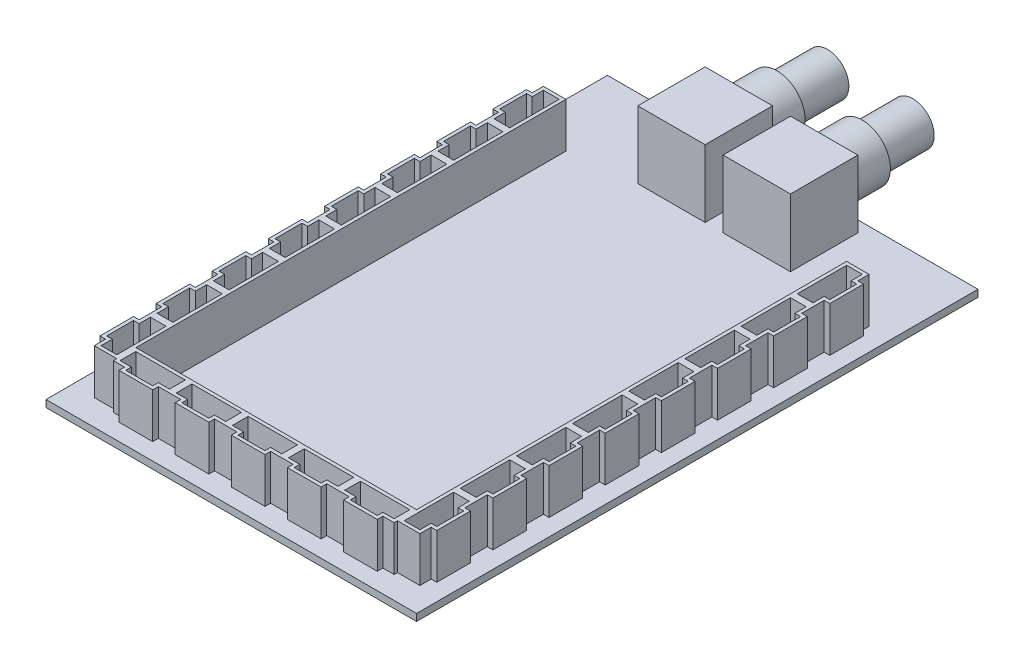
from build123d import *

# Parameters (mm, degrees)
SKETCH1_W            = 83.82
SKETCH1_H            = 127
BOSS_EXTRUDE1_DEPTH  = 1.5875
SKETCH2_W            = 15.24
SKETCH2_H            = 15.24
BNC_BASE_DEPTH       = 15.24
SKETCH3_R            = 6.35
BNC_SHAFT_DEPTH      = 8.636
SKETCH4_R            = 4.826
SKETCH4_R_2          = 4.191
BNC_SHIELD_DEPTH     = 11.43
SKETCH5_W            = 2.413
SKETCH5_H            = 15.748
SKETCH5_H_2          = 20.828
BASEHEADERS_DEPTH    = 2.413
BOSS_EXTRUDE6_DEPTH  = 10.16
LPATTERN1_COUNT      = 8
LPATTERN1_PITCH      = 12.7
MIRROR1_COPY_1_DEPTH = 10.16
MIRROR1_COPY_2_DEPTH = 10.16
MIRROR1_COPY_3_DEPTH = 10.16
MIRROR1_COPY_4_DEPTH = 10.16
MIRROR1_COPY_5_DEPTH = 10.16
MIRROR1_COPY_6_DEPTH = 10.16
MIRROR1_COPY_7_DEPTH = 10.16
BOSS_EXTRUDE7_DEPTH  = 10.16
LPATTERN2_COUNT      = 5
LPATTERN2_PITCH      = 12.7


with BuildPart() as part:
    # Sketch1 → Boss-Extrude1 (new body)
    with BuildSketch(Plane(origin=(0, 0, 0), x_dir=(1, 0, 0), z_dir=(0, 1, 0))):
        Rectangle(SKETCH1_W, SKETCH1_H)
    extrude(amount=BOSS_EXTRUDE1_DEPTH)

    # Sketch2 → BNC Base (add)
    with BuildSketch(Plane(origin=(0, 1.5875, 0), x_dir=(1, 0, 0), z_dir=(0, 1, 0))):
        with Locations((-9.652, 53.34)):
            Rectangle(SKETCH2_W, SKETCH2_H)
        with Locations((9.652, 53.34)):
            Rectangle(SKETCH2_W, SKETCH2_H)
    extrude(amount=BNC_BASE_DEPTH)

    # Sketch3 → BNC Shaft (add)
    with BuildSketch(Plane(origin=(0, 0, -60.96), x_dir=(-1, 0, 0), z_dir=(0, 0, -1))):
        with Locations((-9.652, 9.2075)):
            Circle(SKETCH3_R)
        with Locations((9.652, 9.2075)):
            Circle(SKETCH3_R)
    extrude(amount=BNC_SHAFT_DEPTH)

    # Sketch4 → BNC Shield (add)
    with BuildSketch(Plane(origin=(0, 0, -69.596), x_dir=(-1, 0, 0), z_dir=(0, 0, -1))):
        with Locations((-9.652, 9.2075)):
            Circle(SKETCH4_R)
        with Locations((-9.652, 9.2075)):
            Circle(SKETCH4_R_2, mode=Mode.SUBTRACT)
        with Locations((9.652, 9.2075)):
            Circle(SKETCH4_R)
        with Locations((9.652, 9.2075)):
            Circle(SKETCH4_R_2, mode=Mode.SUBTRACT)
    extrude(amount=BNC_SHIELD_DEPTH)

    # Sketch5 → BaseHeaders (add)
    with BuildSketch(Plane.XZ):
        with Locations((-24.13, -24.13)):
            Rectangle(SKETCH5_W, SKETCH5_H)
        with Locations((24.13, -30.734)):
            Rectangle(SKETCH5_W, SKETCH5_H_2)
        with Locations((24.13, -8.89)):
            Rectangle(SKETCH5_W, SKETCH5_H_2)
        with Locations((24.13, 13.97)):
            Rectangle(SKETCH5_W, SKETCH5_H_2)
        with Locations((-24.13, -3.81)):
            Rectangle(SKETCH5_W, SKETCH5_H_2)
        with Locations((-24.13, 19.05)):
            Rectangle(SKETCH5_W, SKETCH5_H_2)
    extrude(amount=BASEHEADERS_DEPTH)

    # Sketch6 → Boss-Extrude6 (add)
    with BuildSketch(Plane(origin=(0, 1.5875, 0), x_dir=(1, 0, 0), z_dir=(0, 1, 0))):
        Polygon((-36.83, 43.942), (-31.75, 43.942), (-31.75, 31.242), (-36.83, 31.242), (-36.83, 33.782), (-38.1, 33.782), (-38.1, 41.402), (-36.83, 41.402), align=None)
        Polygon((-37.338, 34.544), (-37.338, 40.64), (-36.068, 40.64), (-36.068, 43.18), (-32.512, 43.18), (-32.512, 32.004), (-36.068, 32.004), (-36.068, 34.544), align=None, mode=Mode.SUBTRACT)
    boss_extrude6 = extrude(amount=BOSS_EXTRUDE6_DEPTH)

    # LPattern1: Boss-Extrude6 ×8
    with Locations(*[(0, 0, i * LPATTERN1_PITCH) for i in range(1, LPATTERN1_COUNT)]):
        add(boss_extrude6)

    # Mirror1: Boss-Extrude6 across plane
    add(boss_extrude6.mirror(Plane(origin=(0, 0, 0), x_dir=(0, 0, 1), z_dir=(1, 0, 0))))

    # Mirror1 copy 1 sketch → Mirror1 copy 1 (add)
    with BuildSketch(Plane(origin=(0, 1.5875, 12.7), x_dir=(-1, 0, 0), z_dir=(0, 1, 0))):
        Polygon((-36.83, -43.942), (-31.75, -43.942), (-31.75, -31.242), (-36.83, -31.242), (-36.83, -33.782), (-38.1, -33.782), (-38.1, -41.402), (-36.83, -41.402), align=None)
        Polygon((-37.338, -34.544), (-37.338, -40.64), (-36.068, -40.64), (-36.068, -43.18), (-32.512, -43.18), (-32.512, -32.004), (-36.068, -32.004), (-36.068, -34.544), align=None, mode=Mode.SUBTRACT)
    extrude(amount=MIRROR1_COPY_1_DEPTH)

    # Mirror1 copy 2 sketch → Mirror1 copy 2 (add)
    with BuildSketch(Plane(origin=(0, 1.5875, 25.4), x_dir=(-1, 0, 0), z_dir=(0, 1, 0))):
        Polygon((-36.83, -43.942), (-31.75, -43.942), (-31.75, -31.242), (-36.83, -31.242), (-36.83, -33.782), (-38.1, -33.782), (-38.1, -41.402), (-36.83, -41.402), align=None)
        Polygon((-37.338, -34.544), (-37.338, -40.64), (-36.068, -40.64), (-36.068, -43.18), (-32.512, -43.18), (-32.512, -32.004), (-36.068, -32.004), (-36.068, -34.544), align=None, mode=Mode.SUBTRACT)
    extrude(amount=MIRROR1_COPY_2_DEPTH)

    # Mirror1 copy 3 sketch → Mirror1 copy 3 (add)
    with BuildSketch(Plane(origin=(0, 1.5875, 38.1), x_dir=(-1, 0, 0), z_dir=(0, 1, 0))):
        Polygon((-36.83, -43.942), (-31.75, -43.942), (-31.75, -31.242), (-36.83, -31.242), (-36.83, -33.782), (-38.1, -33.782), (-38.1, -41.402), (-36.83, -41.402), align=None)
        Polygon((-37.338, -34.544), (-37.338, -40.64), (-36.068, -40.64), (-36.068, -43.18), (-32.512, -43.18), (-32.512, -32.004), (-36.068, -32.004), (-36.068, -34.544), align=None, mode=Mode.SUBTRACT)
    extrude(amount=MIRROR1_COPY_3_DEPTH)

    # Mirror1 copy 4 sketch → Mirror1 copy 4 (add)
    with BuildSketch(Plane(origin=(0, 1.5875, 50.8), x_dir=(-1, 0, 0), z_dir=(0, 1, 0))):
        Polygon((-36.83, -43.942), (-31.75, -43.942), (-31.75, -31.242), (-36.83, -31.242), (-36.83, -33.782), (-38.1, -33.782), (-38.1, -41.402), (-36.83, -41.402), align=None)
        Polygon((-37.338, -34.544), (-37.338, -40.64), (-36.068, -40.64), (-36.068, -43.18), (-32.512, -43.18), (-32.512, -32.004), (-36.068, -32.004), (-36.068, -34.544), align=None, mode=Mode.SUBTRACT)
    extrude(amount=MIRROR1_COPY_4_DEPTH)

    # Mirror1 copy 5 sketch → Mirror1 copy 5 (add)
    with BuildSketch(Plane(origin=(0, 1.5875, 63.5), x_dir=(-1, 0, 0), z_dir=(0, 1, 0))):
        Polygon((-36.83, -43.942), (-31.75, -43.942), (-31.75, -31.242), (-36.83, -31.242), (-36.83, -33.782), (-38.1, -33.782), (-38.1, -41.402), (-36.83, -41.402), align=None)
        Polygon((-37.338, -34.544), (-37.338, -40.64), (-36.068, -40.64), (-36.068, -43.18), (-32.512, -43.18), (-32.512, -32.004), (-36.068, -32.004), (-36.068, -34.544), align=None, mode=Mode.SUBTRACT)
    extrude(amount=MIRROR1_COPY_5_DEPTH)

    # Mirror1 copy 6 sketch → Mirror1 copy 6 (add)
    with BuildSketch(Plane(origin=(0, 1.5875, 76.2), x_dir=(-1, 0, 0), z_dir=(0, 1, 0))):
        Polygon((-36.83, -43.942), (-31.75, -43.942), (-31.75, -31.242), (-36.83, -31.242), (-36.83, -33.782), (-38.1, -33.782), (-38.1, -41.402), (-36.83, -41.402), align=None)
        Polygon((-37.338, -34.544), (-37.338, -40.64), (-36.068, -40.64), (-36.068, -43.18), (-32.512, -43.18), (-32.512, -32.004), (-36.068, -32.004), (-36.068, -34.544), align=None, mode=Mode.SUBTRACT)
    extrude(amount=MIRROR1_COPY_6_DEPTH)

    # Mirror1 copy 7 sketch → Mirror1 copy 7 (add)
    with BuildSketch(Plane(origin=(0, 1.5875, 88.9), x_dir=(-1, 0, 0), z_dir=(0, 1, 0))):
        Polygon((-36.83, -43.942), (-31.75, -43.942), (-31.75, -31.242), (-36.83, -31.242), (-36.83, -33.782), (-38.1, -33.782), (-38.1, -41.402), (-36.83, -41.402), align=None)
        Polygon((-37.338, -34.544), (-37.338, -40.64), (-36.068, -40.64), (-36.068, -43.18), (-32.512, -43.18), (-32.512, -32.004), (-36.068, -32.004), (-36.068, -34.544), align=None, mode=Mode.SUBTRACT)
    extrude(amount=MIRROR1_COPY_7_DEPTH)

    # Sketch7 → Boss-Extrude7 (add)
    with BuildSketch(Plane(origin=(0, 1.5875, 0), x_dir=(1, 0, 0), z_dir=(0, 1, 0))):
        Polygon((-31.75, -58.42), (-31.75, -53.34), (-19.05, -53.34), (-19.05, -58.42), (-21.59, -58.42), (-21.59, -59.69), (-29.21, -59.69), (-29.21, -58.42), align=None)
        Polygon((-22.352, -58.928), (-28.448, -58.928), (-28.448, -57.658), (-30.988, -57.658), (-30.988, -54.102), (-19.812, -54.102), (-19.812, -57.658), (-22.352, -57.658), align=None, mode=Mode.SUBTRACT)
    boss_extrude7 = extrude(amount=BOSS_EXTRUDE7_DEPTH)

    # LPattern2: Boss-Extrude7 ×5
    with Locations(*[(i * LPATTERN2_PITCH, 0, 0) for i in range(1, LPATTERN2_COUNT)]):
        add(boss_extrude7)


solid = part.part
